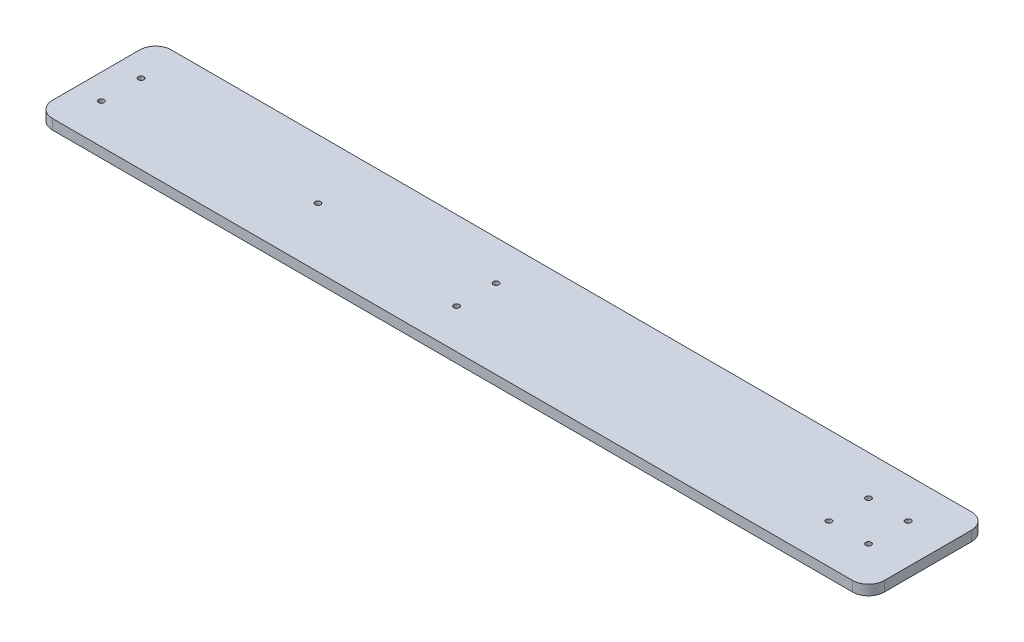
from build123d import *

# Parameters (mm, degrees)
SKETCH12_W                = 525
SKETCH12_H                = 75
BOSS_EXTRUDE2_DEPTH       = 6.35
SKETCH13_R                = 1.75
CUT_EXTRUDE1_DEPTH        = 7.35
LPATTERN1_COUNT           = 2
LPATTERN1_PITCH           = 25
LPATTERN2_COUNT           = 2
LPATTERN2_PITCH           = 25
LPATTERN2_COPY_1_SKETCH_R = 1.75
LPATTERN2_COPY_1_DEPTH    = 7.35
SKETCH15_R                = 1.75
CUT_EXTRUDE2_DEPTH        = 7.35
FILLET1_R                 = 10
SKETCH17_R                = 1.75
CUT_EXTRUDE3_DEPTH        = 7.35
SKETCH18_R                = 1.75
CUT_EXTRUDE4_DEPTH        = 7.35


with BuildPart() as part:
    # Sketch12 → Boss-Extrude2 (new body)
    with BuildSketch(Plane(origin=(0, 0, 0), x_dir=(1, 0, 0), z_dir=(0, 1, 0))):
        Rectangle(SKETCH12_W, SKETCH12_H)
    extrude(amount=BOSS_EXTRUDE2_DEPTH)

    # Sketch13 → Cut-Extrude1 (cut, through all)
    with BuildSketch(Plane.XZ):
        with Locations((212.5, -12.5)):
            Circle(SKETCH13_R)
    cut_extrude1 = extrude(amount=-CUT_EXTRUDE1_DEPTH, mode=Mode.SUBTRACT)

    # LPattern1: Cut-Extrude1 ×2
    with Locations(*[(i * LPATTERN1_PITCH, 0, 0) for i in range(1, LPATTERN1_COUNT)]):
        add(cut_extrude1, mode=Mode.SUBTRACT)

    # LPattern2: Cut-Extrude1 ×2
    with Locations(*[(0, 0, i * LPATTERN2_PITCH) for i in range(1, LPATTERN2_COUNT)]):
        add(cut_extrude1, mode=Mode.SUBTRACT)

    # LPattern2 copy 1 sketch → LPattern2 copy 1 (cut, through all)
    with BuildSketch(Plane(origin=(25, 0, 25), x_dir=(1, 0, 0), z_dir=(0, -1, 0))):
        with Locations((212.5, -12.5)):
            Circle(LPATTERN2_COPY_1_SKETCH_R)
    extrude(amount=-LPATTERN2_COPY_1_DEPTH, mode=Mode.SUBTRACT)

    # Sketch15 → Cut-Extrude2 (cut, through all)
    with BuildSketch(Plane.XZ):
        with Locations((-122.5, 0)):
            Circle(SKETCH15_R)
    extrude(amount=-CUT_EXTRUDE2_DEPTH, mode=Mode.SUBTRACT)

    # Fillet1
    fillet1_edges = [part.edges().sort_by_distance(p)[0] for p in [
        (262.5, 3.175, 37.5),
        (-262.5, 3.175, 37.5),
        (-262.5, 3.175, -37.5),
        (262.5, 3.175, -37.5),
    ]]
    fillet(fillet1_edges, radius=FILLET1_R)

    # Sketch17 → Cut-Extrude3 (cut, through all)
    with BuildSketch(Plane(origin=(0, 6.35, 0), x_dir=(1, 0, 0), z_dir=(0, 1, 0))):
        with Locations((-22.5, 12.5)):
            Circle(SKETCH17_R)
        with Locations((-22.5, -12.5)):
            Circle(SKETCH17_R)
    extrude(amount=-CUT_EXTRUDE3_DEPTH, mode=Mode.SUBTRACT)

    # Sketch18 → Cut-Extrude4 (cut, through all)
    with BuildSketch(Plane(origin=(0, 6.35, 0), x_dir=(1, 0, 0), z_dir=(0, 1, 0))):
        with Locations((-246.62, 12.5)):
            Circle(SKETCH18_R)
        with Locations((-246.62, -12.5)):
            Circle(SKETCH18_R)
    extrude(amount=-CUT_EXTRUDE4_DEPTH, mode=Mode.SUBTRACT)


solid = part.part
